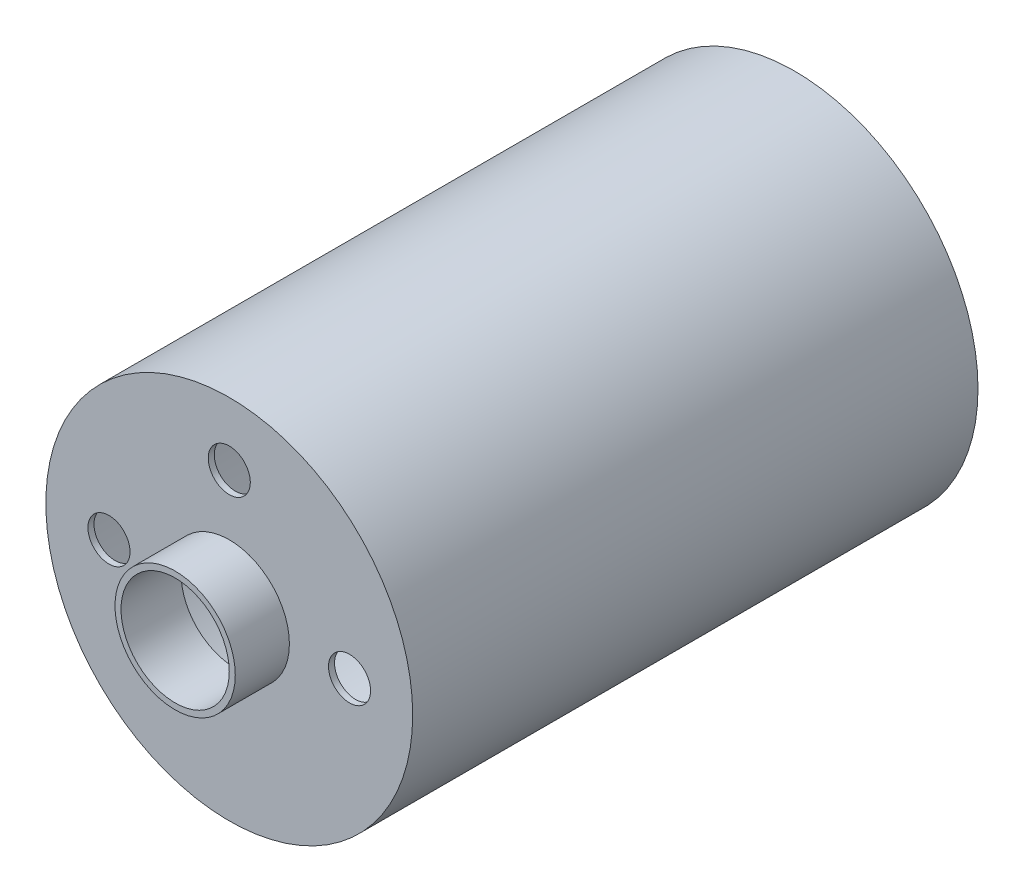
from build123d import *

# Parameters (mm, degrees)
SKETCH1_R           = 15.25
BOSS_EXTRUDE1_DEPTH = 23.5
SKETCH2_R           = 5
BOSS_EXTRUDE2_DEPTH = 4.5
SHELL1_T            = -0.5
SKETCH3_R           = 1.75
CUT_EXTRUDE1_DEPTH  = 4.5


with BuildPart() as part:
    # Sketch1 → Boss-Extrude1 (new, symmetric)
    with BuildSketch(Plane.XY):
        Circle(SKETCH1_R)
    extrude(amount=BOSS_EXTRUDE1_DEPTH, both=True)

    # Sketch2 → Boss-Extrude2 (add)
    with BuildSketch(Plane.XY.offset(23.5)):
        Circle(SKETCH2_R)
    extrude(amount=BOSS_EXTRUDE2_DEPTH)

    # Shell1
    shell1_openings = [part.faces().sort_by_distance(p)[0] for p in [
        (0, 0, -23.5),
        (0, 0, 28),
    ]]
    offset(amount=SHELL1_T, openings=shell1_openings, kind=Kind.INTERSECTION)

    # Sketch3 → Cut-Extrude1 (cut)
    with BuildSketch(Plane.XY.offset(23.5)):
        with Locations((-10, 0)):
            Circle(SKETCH3_R)
        with Locations((0, 10)):
            Circle(SKETCH3_R)
        with Locations((10, 0)):
            Circle(SKETCH3_R)
    extrude(amount=-CUT_EXTRUDE1_DEPTH, mode=Mode.SUBTRACT)


solid = part.part
